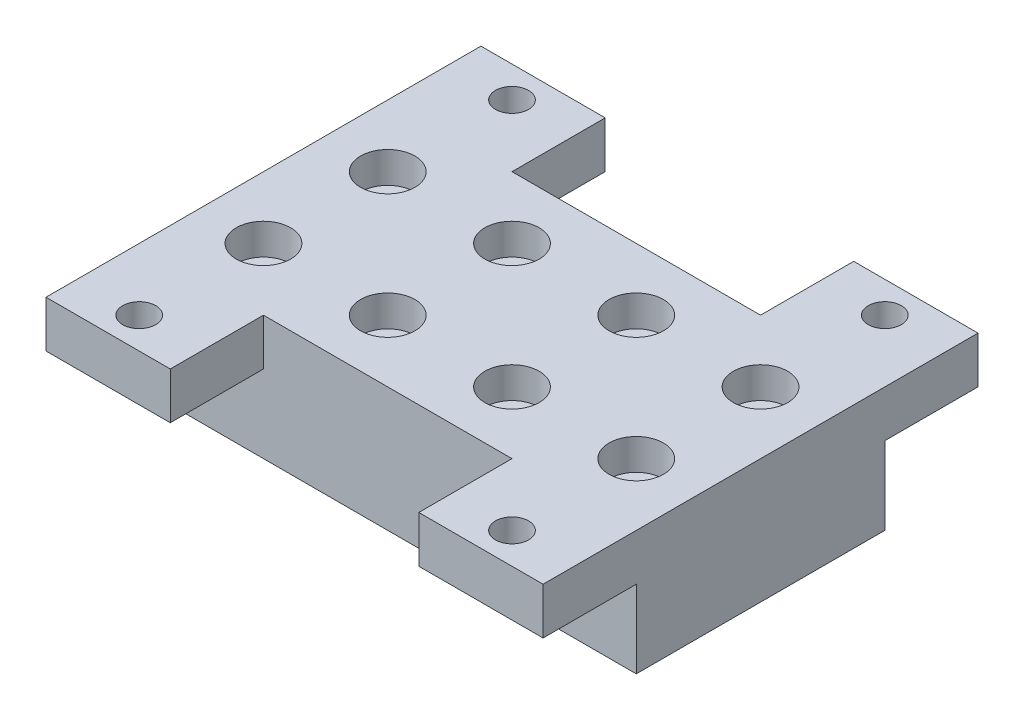
from build123d import *

# Parameters (mm, degrees)
SKETCH1_W                                        = 101.6
SKETCH1_H                                        = 50.8
BOSS_EXTRUDE1_DEPTH                              = 25.4
CBORE_FOR_1_4_SOCKET_HEAD_CAP_SCREW1_D           = 6.7564
CBORE_FOR_1_4_SOCKET_HEAD_CAP_SCREW1_CBORE_D     = 11.1125
CBORE_FOR_1_4_SOCKET_HEAD_CAP_SCREW1_CBORE_DEPTH = 6.35
LPATTERN1_COUNT                                  = 2
LPATTERN1_PITCH                                  = 25.4
LPATTERN1_COUNT_DIR2                             = 4
LPATTERN1_PITCH_DIR2                             = 25.4
F_1_4_CLEARANCE_HOLE1_D                          = 6.7564
LPATTERN2_COUNT                                  = 4
LPATTERN2_PITCH                                  = 25.4
SKETCH7_W                                        = 101.6
SKETCH7_H                                        = 9.525
BOSS_EXTRUDE2_DEPTH                              = 19.05
LPATTERN3_COUNT                                  = 2
LPATTERN3_PITCH                                  = 25.4
LPATTERN4_COPY_1_D                               = 6.7564
LPATTERN4_COPY_2_D                               = 6.7564
SKETCH11_W                                       = 101.6
SKETCH11_H                                       = 9.525
BOSS_EXTRUDE3_DEPTH                              = 19.05
SKETCH8_W                                        = 50.8
SKETCH8_H                                        = 9.525
CUT_EXTRUDE1_DEPTH                               = 19.05
SKETCH12_W                                       = 50.8
SKETCH12_H                                       = 9.525
CUT_EXTRUDE2_DEPTH                               = 19.05
LPATTERN5_COUNT                                  = 2
LPATTERN5_PITCH                                  = 50.8
LPATTERN5_COUNT_DIR2                             = 2
LPATTERN5_PITCH_DIR2                             = 76.2


with BuildPart() as part:
    # Sketch1 → Boss-Extrude1 (new body)
    with BuildSketch(Plane(origin=(0, 0, 0), x_dir=(1, 0, 0), z_dir=(0, 1, 0))):
        with Locations((50.8, 25.4)):
            Rectangle(SKETCH1_W, SKETCH1_H)
    extrude(amount=BOSS_EXTRUDE1_DEPTH)

    # CBORE for 1/4 Socket Head Cap Screw1 (through all)
    with Locations(Plane(origin=(0, 25.4, 0), x_dir=(-1, 0, 0), z_dir=(0, 1, 0))):
        with Locations((-12.7, -12.7)):
            cbore_for_1_4_socket_head_cap_screw1 = CounterBoreHole(CBORE_FOR_1_4_SOCKET_HEAD_CAP_SCREW1_D / 2, CBORE_FOR_1_4_SOCKET_HEAD_CAP_SCREW1_CBORE_D / 2, CBORE_FOR_1_4_SOCKET_HEAD_CAP_SCREW1_CBORE_DEPTH)

    # LPattern1: CBORE for 1_4 Socket Head Cap Screw1 2 × 4
    with Locations(*[(j * LPATTERN1_PITCH_DIR2, 0, -i * LPATTERN1_PITCH) for i in range(LPATTERN1_COUNT) for j in range(LPATTERN1_COUNT_DIR2) if (i, j) != (0, 0)]):
        add(cbore_for_1_4_socket_head_cap_screw1, mode=Mode.SUBTRACT)

    # 1/4 Clearance Hole1 (through all)
    with Locations(Plane(origin=(0, 25.4, 0), x_dir=(-1, 0, 0), z_dir=(0, 1, 0))):
        with Locations((-12.7, -38.1)):
            f_1_4_clearance_hole1 = Hole(F_1_4_CLEARANCE_HOLE1_D / 2)

    # LPattern2: 1/4 Clearance Hole1 ×4
    with Locations(*[(-i * LPATTERN2_PITCH, 0, 0) for i in range(1, LPATTERN2_COUNT)]):
        add(f_1_4_clearance_hole1, mode=Mode.SUBTRACT)

    # Sketch7 → Boss-Extrude2 (add)
    with BuildSketch(Plane(origin=(0, 0, -50.8), x_dir=(-1, 0, 0), z_dir=(0, 0, -1))):
        with Locations((-50.8, 20.6375)):
            Rectangle(SKETCH7_W, SKETCH7_H)
    extrude(amount=BOSS_EXTRUDE2_DEPTH)

    # LPattern3: 1/4 Clearance Hole1 ×2
    with Locations(*[(0, 0, -i * LPATTERN3_PITCH) for i in range(1, LPATTERN3_COUNT)]):
        add(f_1_4_clearance_hole1, mode=Mode.SUBTRACT)

    # LPattern4 copy 1 (through all)
    with Locations(Plane(origin=(76.2, 25.4, -25.4), x_dir=(-1, 0, 0), z_dir=(0, 1, 0))):
        with Locations((-12.7, -38.1)):
            Hole(LPATTERN4_COPY_1_D / 2)

    # LPattern4 copy 2 (through all)
    with Locations(Plane(origin=(76.2, 25.4, 0), x_dir=(-1, 0, 0), z_dir=(0, 1, 0))):
        with Locations((-12.7, -38.1)):
            Hole(LPATTERN4_COPY_2_D / 2)

    # Sketch11 → Boss-Extrude3 (add)
    with BuildSketch(Plane.XY):
        with Locations((50.8, 20.6375)):
            Rectangle(SKETCH11_W, SKETCH11_H)
    extrude(amount=BOSS_EXTRUDE3_DEPTH)

    # Sketch8 → Cut-Extrude1 (cut)
    with BuildSketch(Plane(origin=(0, 0, -69.85), x_dir=(-1, 0, 0), z_dir=(0, 0, -1))):
        with Locations((-50.8, 20.6375)):
            Rectangle(SKETCH8_W, SKETCH8_H)
    extrude(amount=-CUT_EXTRUDE1_DEPTH, mode=Mode.SUBTRACT)

    # Sketch12 → Cut-Extrude2 (cut)
    with BuildSketch(Plane.XY.offset(19.05)):
        with Locations((50.8, 20.6375)):
            Rectangle(SKETCH12_W, SKETCH12_H)
    extrude(amount=-CUT_EXTRUDE2_DEPTH, mode=Mode.SUBTRACT)

    # LPattern5: 1_4 Clearance Hole1 2 × 2
    with Locations(*[(j * LPATTERN5_PITCH_DIR2, 0, i * LPATTERN5_PITCH) for i in range(LPATTERN5_COUNT) for j in range(LPATTERN5_COUNT_DIR2) if (i, j) != (0, 0)]):
        add(f_1_4_clearance_hole1, mode=Mode.SUBTRACT)


solid = part.part
